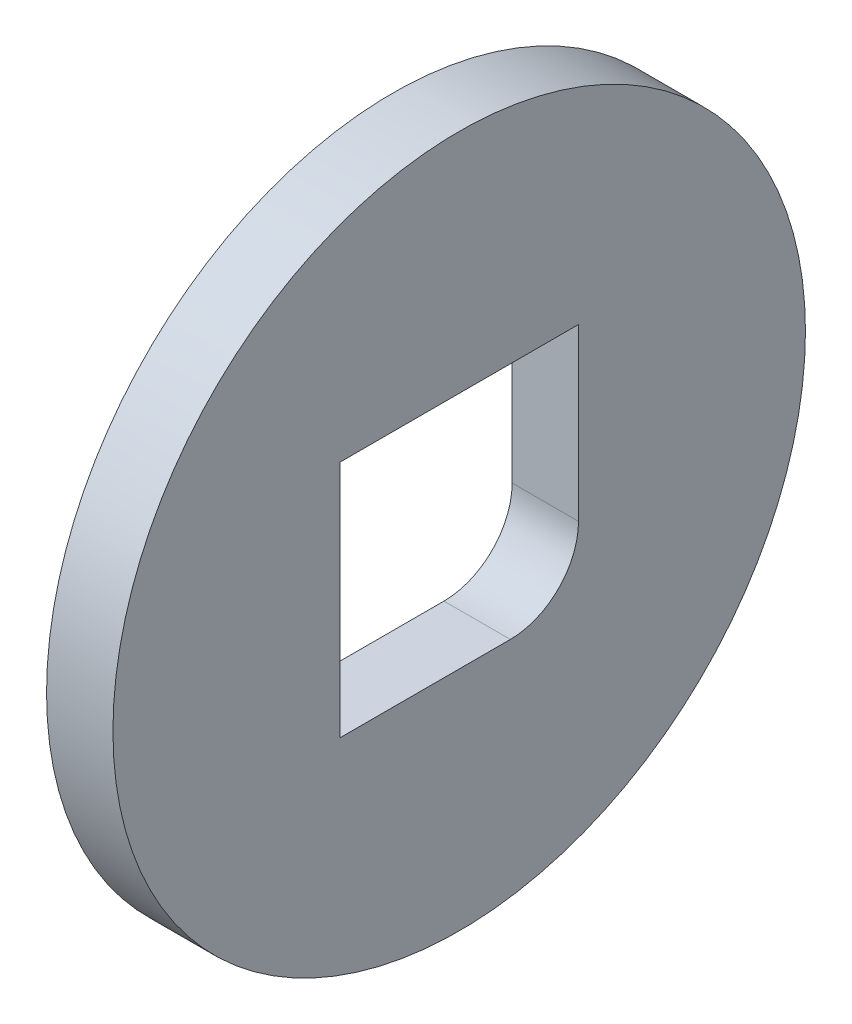
from build123d import *

# Parameters (mm, degrees)
ESQUISSE1_W             = 9.734075662
ESQUISSE1_H             = 50.777874564
ESQUISSE2_W             = 35
ESQUISSE2_H             = 35
ENL_V_MAT_EXTRU_1_DEPTH = 10.734075662
CONG_2_R                = 10


with BuildPart() as part:
    # Esquisse1 → Révolution1 (revolve)
    with BuildSketch(Plane.XY, mode=Mode.PRIVATE) as r_volution1_sk:
        with Locations((4.867037831, 25.388937282)):
            Rectangle(ESQUISSE1_W, ESQUISSE1_H)
    revolve(r_volution1_sk.sketch.rotate(Axis((9.734075662, 0, 0), (-1, 0, 0)), 90), axis=Axis((9.734075662, 0, 0), (-1, 0, 0)))  # turned: the seam where the file's is

    # Esquisse2 → Enlèv. mat.-Extru.1 (cut, through all)
    with BuildSketch(Plane(origin=(9.734075662, 0, 0), x_dir=(0, 0, -1), z_dir=(1, 0, 0))):
        Rectangle(ESQUISSE2_W, ESQUISSE2_H)
    extrude(amount=-ENL_V_MAT_EXTRU_1_DEPTH, mode=Mode.SUBTRACT)

    # Congé2
    cong_2_edges = [part.edges().sort_by_distance(p)[0] for p in [
        (4.867037831, -17.5, -17.5),
    ]]
    fillet(cong_2_edges, radius=CONG_2_R)


solid = part.part
